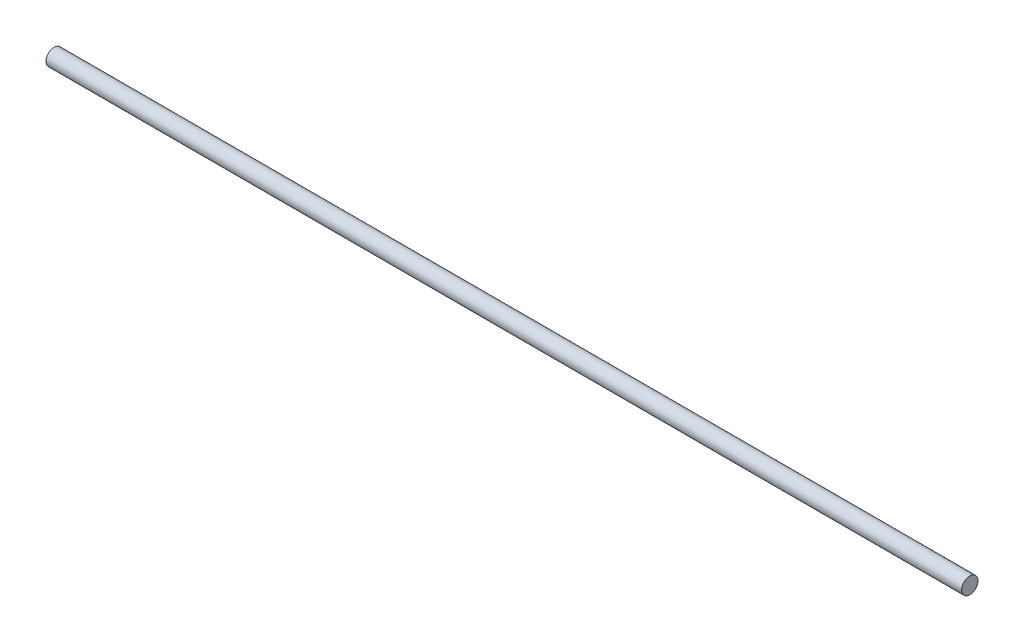
from build123d import *

# Parameters (mm, degrees)
SKETCH1_R           = 2.5
BOSS_EXTRUDE1_DEPTH = 280


with BuildPart() as part:
    # Sketch1 → Boss-Extrude1 (new body)
    with BuildSketch(Plane(origin=(0, 0, 0), x_dir=(0, 0, -1), z_dir=(1, 0, 0))):
        Circle(SKETCH1_R)
    extrude(amount=BOSS_EXTRUDE1_DEPTH)


solid = part.part
